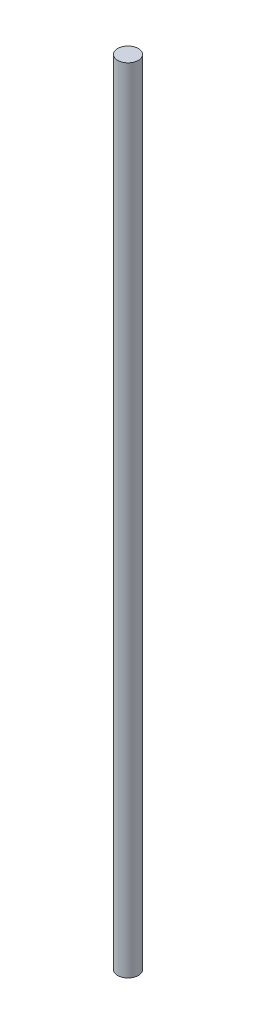
from build123d import *

# Parameters (mm, degrees)
SKETCH1_R           = 3.96875
BOSS_EXTRUDE1_DEPTH = 304.8


with BuildPart() as part:
    # Sketch1 → Boss-Extrude1 (new body)
    with BuildSketch(Plane(origin=(0, 0, 0), x_dir=(1, 0, 0), z_dir=(0, 1, 0))):
        Circle(SKETCH1_R)
    extrude(amount=BOSS_EXTRUDE1_DEPTH)


solid = part.part
